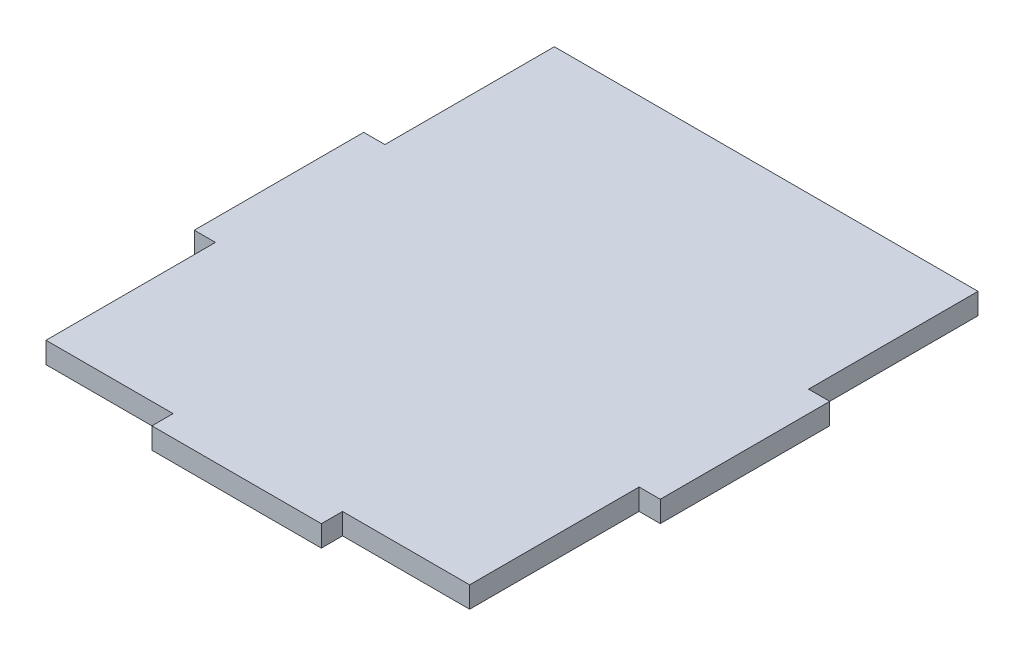
from build123d import *

# Parameters (mm, degrees)
BOSS_EXTRUDE1_DEPTH     = 6.35
SKETCH2_W               = 38.1
SKETCH2_H               = 6.35
CUT_EXTRUDE1_DEPTH      = 6.35
CUT_EXTRUDE1_DEPTH_BACK = 13.97


with BuildPart() as part:
    # Sketch1 → Boss-Extrude1 (new body)
    with BuildSketch(Plane(origin=(0, 0, 0), x_dir=(1, 0, 0), z_dir=(0, 1, 0))):
        Polygon((-63.5, -79.375), (63.5, -79.375), (63.5, -22.225), (69.85, -22.225), (69.85, 28.575), (63.5, 28.575), (63.5, 79.375), (-63.5, 79.375), (-63.5, 28.575), (-69.85, 28.575), (-69.85, -22.225), (-63.5, -22.225), align=None)
    extrude(amount=BOSS_EXTRUDE1_DEPTH)

    # Sketch2 → Cut-Extrude1 (cut, two sides)
    with BuildSketch(Plane(origin=(0, 6.35, 0), x_dir=(1, 0, 0), z_dir=(0, 1, 0))) as cut_extrude1_sk:
        with Locations((-44.45, -76.2)):
            Rectangle(SKETCH2_W, SKETCH2_H)
        with Locations((44.45, -76.2)):
            Rectangle(SKETCH2_W, SKETCH2_H)
    extrude(amount=CUT_EXTRUDE1_DEPTH, mode=Mode.SUBTRACT)
    extrude(cut_extrude1_sk.sketch, amount=-CUT_EXTRUDE1_DEPTH_BACK, mode=Mode.SUBTRACT)


solid = part.part
